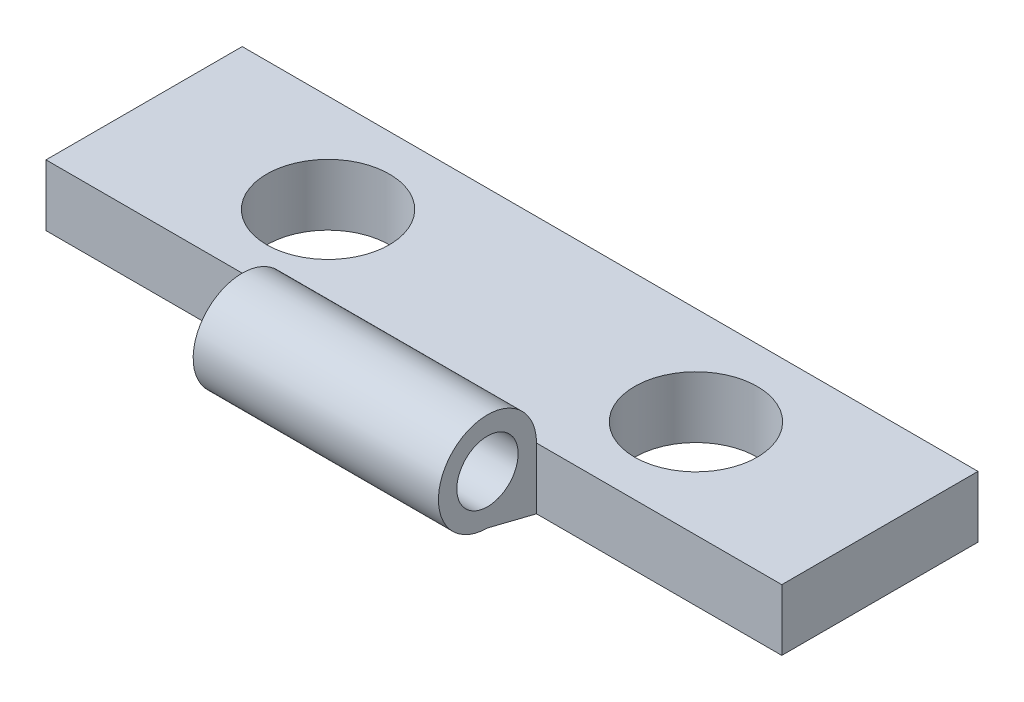
from build123d import *

# Parameters (mm, degrees)
SKETCH1_W                       = 30
SKETCH1_H                       = 8
SKETCH1_R                       = 2.5
BOSS_EXTRUDE1_DEPTH             = 2.5
BOSS_EXTRUDE2_REACH             = 17
SKETCH2_R                       = 1.25
BOSS_EXTRUDE2_DIRECTION_2_REACH = 17
SKETCH4_W                       = 10
SKETCH4_H                       = 4
CUT_EXTRUDE2_DEPTH              = 5.5


with BuildPart() as part:
    # Sketch1 → Boss-Extrude1 (new body)
    with BuildSketch(Plane(origin=(0, 0, 0), x_dir=(1, 0, 0), z_dir=(0, 1, 0))):
        Rectangle(SKETCH1_W, SKETCH1_H)
        with Locations((-7.5, 0)):
            Circle(SKETCH1_R, mode=Mode.SUBTRACT)
        with Locations((7.5, 0)):
            Circle(SKETCH1_R, mode=Mode.SUBTRACT)
    extrude(amount=BOSS_EXTRUDE1_DEPTH)

    # Boss-Extrude2: up to this face of the body (flat: up to its plane)
    boss_extrude2_end = Plane(part.part.faces().sort_by_distance((15, 1.25, 0))[0])
    # Sketch2 → Boss-Extrude2 (add, up to the picked face)
    with BuildSketch(Plane(origin=(0, 0, 0), x_dir=(0, 0, -1), z_dir=(1, 0, 0)), mode=Mode.PRIVATE) as boss_extrude2_sk1:
        with BuildLine():
            Line((-4, 2.5), (-4, 0))
            Line((-4, 0), (-6, 0.5))
            ThreePointArc((-6, 0.5), (-7.414213562, 3.914213562), (-4, 2.5))
        make_face()
        with Locations((-6, 2.5)):
            Circle(SKETCH2_R, mode=Mode.SUBTRACT)
    boss_extrude2_tool1 = split(extrude(boss_extrude2_sk1.sketch, amount=BOSS_EXTRUDE2_REACH, mode=Mode.PRIVATE), bisect_by=boss_extrude2_end, keep=Keep.BOTH, mode=Mode.PRIVATE)
    add(boss_extrude2_tool1.solids().sort_by_distance((0, 1.25, 4.060208))[0])

    # Boss-Extrude2 direction 2: up to this face of the body (flat: up to its plane)
    boss_extrude2_direction_2_end = Plane(part.part.faces().sort_by_distance((-15, 1.25, 0))[0])
    # Sketch2 → Boss-Extrude2 direction 2 (add, up to the picked face)
    with BuildSketch(Plane(origin=(0, 0, 0), x_dir=(0, 0, -1), z_dir=(1, 0, 0)), mode=Mode.PRIVATE) as boss_extrude2_direction_2_sk1:
        with BuildLine():
            Line((-4, 2.5), (-4, 0))
            Line((-4, 0), (-6, 0.5))
            ThreePointArc((-6, 0.5), (-7.414213562, 3.914213562), (-4, 2.5))
        make_face()
        with Locations((-6, 2.5)):
            Circle(SKETCH2_R, mode=Mode.SUBTRACT)
    boss_extrude2_direction_2_tool1 = split(extrude(boss_extrude2_direction_2_sk1.sketch, amount=-BOSS_EXTRUDE2_DIRECTION_2_REACH, mode=Mode.PRIVATE), bisect_by=boss_extrude2_direction_2_end, keep=Keep.BOTH, mode=Mode.PRIVATE)
    add(boss_extrude2_direction_2_tool1.solids().sort_by_distance((0, 1.25, 4.060208))[0])

    # Sketch4 → Cut-Extrude2 (cut, through all)
    with BuildSketch(Plane(origin=(0, 0, 0), x_dir=(1, 0, 0), z_dir=(0, 1, 0))):
        with Locations((-10, -6)):
            Rectangle(SKETCH4_W, SKETCH4_H)
        with Locations((10, -6)):
            Rectangle(SKETCH4_W, SKETCH4_H)
    extrude(amount=CUT_EXTRUDE2_DEPTH, mode=Mode.SUBTRACT)


solid = part.part
